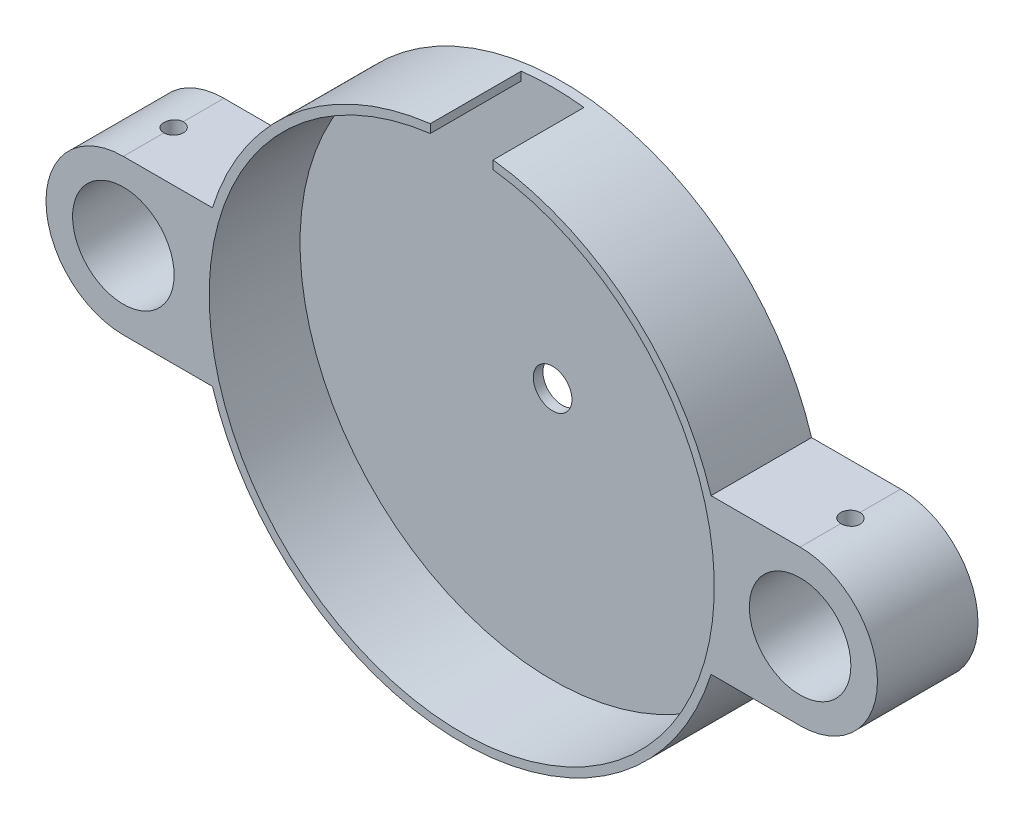
from build123d import *

# Parameters (mm, degrees)
SKETCH1_R           = 54
BOSS_EXTRUDE1_DEPTH = 20.8
CUT_EXTRUDE2_START  = 2
SKETCH2_R           = 52.25
CUT_EXTRUDE2_DEPTH  = 18.8
SKETCH3_R           = 10.5
BOSS_EXTRUDE2_DEPTH = 20.8
SKETCH4_R           = 4
CUT_EXTRUDE3_DEPTH  = 2
CUT_EXTRUDE4_START  = 2
SKETCH5_W           = 13
SKETCH5_H           = 59.759182194
CUT_EXTRUDE4_DEPTH  = 18.8
SKETCH6_R           = 2
CUT_EXTRUDE5_DEPTH  = 16


with BuildPart() as part:
    # Sketch1 → Boss-Extrude1 (new body)
    with BuildSketch(Plane.XY):
        Circle(SKETCH1_R)
    extrude(amount=BOSS_EXTRUDE1_DEPTH)

    # Sketch2 → Cut-Extrude2 (cut)
    with BuildSketch(Plane.XY.offset(CUT_EXTRUDE2_START)):
        Circle(SKETCH2_R)
    extrude(amount=CUT_EXTRUDE2_DEPTH, mode=Mode.SUBTRACT)

    # Sketch3 → Boss-Extrude2 (add)
    with BuildSketch(Plane.XY):
        with BuildLine():
            ThreePointArc((-51.575187833, 16), (-54, 0), (-51.575187833, -16))
            Line((-51.575187833, -16), (-70, -16))
            ThreePointArc((-70, -16), (-86, 0), (-70, 16))
            Line((-70, 16), (-51.575187833, 16))
        make_face()
        with Locations((-70, 0)):
            Circle(SKETCH3_R, mode=Mode.SUBTRACT)
        with BuildLine():
            Line((70, 16), (51.575187833, 16))
            ThreePointArc((51.575187833, 16), (54, 0), (51.575187833, -16))
            Line((51.575187833, -16), (70, -16))
            ThreePointArc((70, -16), (86, 0), (70, 16))
        make_face()
        with Locations((70, 0)):
            Circle(SKETCH3_R, mode=Mode.SUBTRACT)
    extrude(amount=BOSS_EXTRUDE2_DEPTH)

    # Sketch4 → Cut-Extrude3 (cut)
    with BuildSketch(Plane.XY):
        Circle(SKETCH4_R)
    extrude(amount=CUT_EXTRUDE3_DEPTH, mode=Mode.SUBTRACT)

    # Sketch5 → Cut-Extrude4 (cut)
    with BuildSketch(Plane.XY.offset(CUT_EXTRUDE4_START)):
        with Locations((0, 29.879591097)):
            Rectangle(SKETCH5_W, SKETCH5_H)
    extrude(amount=CUT_EXTRUDE4_DEPTH, mode=Mode.SUBTRACT)

    # Sketch6 → Cut-Extrude5 (cut)
    with BuildSketch(Plane(origin=(0, 0, 0), x_dir=(1, 0, 0), z_dir=(0, 1, 0))):
        with Locations((-70, -10.4)):
            Circle(SKETCH6_R)
        with Locations((70, -10.4)):
            Circle(SKETCH6_R)
    extrude(amount=CUT_EXTRUDE5_DEPTH, mode=Mode.SUBTRACT)


solid = part.part
